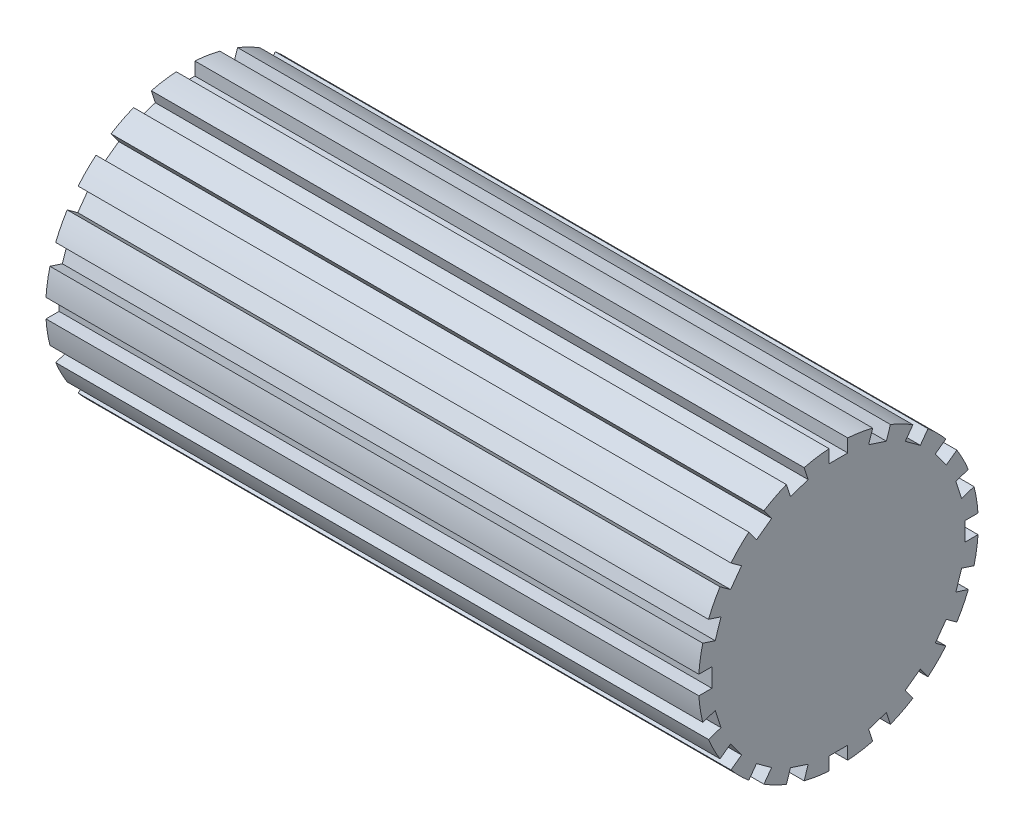
from build123d import *

# Parameters (mm, degrees)
SKETCH1_W          = 44.45
SKETCH1_H          = 9.525
SKETCH2_OUTSIDE_W  = 31.446
SKETCH2_OUTSIDE_H  = 31.446
CUT_EXTRUDE1_DEPTH = 44.45


with BuildPart() as part:
    # Sketch1 → Revolve1 (revolve)
    with BuildSketch(Plane(origin=(0, 0, 0), x_dir=(1, 0, 0), z_dir=(0, 1, 0))):
        with Locations((0, 4.7625)):
            Rectangle(SKETCH1_W, SKETCH1_H)
    revolve(axis=Axis((17.670033956, 0, 0), (-1, 0, 0)))

    # Sketch2 outside → Cut-Extrude1 (cut)
    with BuildSketch(Plane(origin=(22.225, 0, 0), x_dir=(0, 0, -1), z_dir=(1, 0, 0))):
        Rectangle(SKETCH2_OUTSIDE_W, SKETCH2_OUTSIDE_H)
        with BuildLine():
            Line((-0.635, 8.614809762), (0.635, 8.614809762))
            Line((0.635, 8.614809762), (0.635, 9.503809762))
            ThreePointArc((0.635, 9.503809762), (1.49003828, 9.407731444), (2.33291784, 9.234885996))
            Line((2.33291784, 9.234885996), (2.058201732, 8.389396753))
            Line((2.058201732, 8.389396753), (3.266043508, 7.99694517))
            Line((3.266043508, 7.99694517), (3.540759616, 8.842434413))
            ThreePointArc((3.540759616, 8.842434413), (4.32425951, 8.486837143), (5.072473428, 8.061987244))
            Line((5.072473428, 8.061987244), (4.549932338, 7.342771136))
            Line((4.549932338, 7.342771136), (5.577383921, 6.596283866))
            Line((5.577383921, 6.596283866), (6.09992501, 7.315499974))
            ThreePointArc((6.09992501, 7.315499974), (6.735192091, 6.735192091), (7.315499974, 6.09992501))
            Line((7.315499974, 6.09992501), (6.596283866, 5.577383921))
            Line((6.596283866, 5.577383921), (7.342771136, 4.549932338))
            Line((7.342771136, 4.549932338), (8.061987244, 5.072473428))
            ThreePointArc((8.061987244, 5.072473428), (8.486837143, 4.32425951), (8.842434413, 3.540759616))
            Line((8.842434413, 3.540759616), (7.99694517, 3.266043508))
            Line((7.99694517, 3.266043508), (8.389396753, 2.058201732))
            Line((8.389396753, 2.058201732), (9.234885996, 2.33291784))
            ThreePointArc((9.234885996, 2.33291784), (9.407731444, 1.49003828), (9.503809762, 0.635))
            Line((9.503809762, 0.635), (8.614809762, 0.635))
            Line((8.614809762, 0.635), (8.614809762, -0.635))
            Line((8.614809762, -0.635), (9.503809762, -0.635))
            ThreePointArc((9.503809762, -0.635), (9.407731444, -1.49003828), (9.234885996, -2.33291784))
            Line((9.234885996, -2.33291784), (8.389396753, -2.058201732))
            Line((8.389396753, -2.058201732), (7.99694517, -3.266043508))
            Line((7.99694517, -3.266043508), (8.842434413, -3.540759616))
            ThreePointArc((8.842434413, -3.540759616), (8.486837143, -4.32425951), (8.061987244, -5.072473428))
            Line((8.061987244, -5.072473428), (7.342771136, -4.549932338))
            Line((7.342771136, -4.549932338), (6.596283866, -5.577383921))
            Line((6.596283866, -5.577383921), (7.315499974, -6.09992501))
            ThreePointArc((7.315499974, -6.09992501), (6.735192091, -6.735192091), (6.09992501, -7.315499974))
            Line((6.09992501, -7.315499974), (5.577383921, -6.596283866))
            Line((5.577383921, -6.596283866), (4.549932338, -7.342771136))
            Line((4.549932338, -7.342771136), (5.072473428, -8.061987244))
            ThreePointArc((5.072473428, -8.061987244), (4.32425951, -8.486837143), (3.540759616, -8.842434413))
            Line((3.540759616, -8.842434413), (3.266043508, -7.99694517))
            Line((3.266043508, -7.99694517), (2.058201732, -8.389396753))
            Line((2.058201732, -8.389396753), (2.33291784, -9.234885996))
            ThreePointArc((2.33291784, -9.234885996), (1.49003828, -9.407731444), (0.635, -9.503809762))
            Line((0.635, -9.503809762), (0.635, -8.614809762))
            Line((0.635, -8.614809762), (-0.635, -8.614809762))
            Line((-0.635, -8.614809762), (-0.635, -9.503809762))
            ThreePointArc((-0.635, -9.503809762), (-1.49003828, -9.407731444), (-2.33291784, -9.234885996))
            Line((-2.33291784, -9.234885996), (-2.058201732, -8.389396753))
            Line((-2.058201732, -8.389396753), (-3.266043508, -7.99694517))
            Line((-3.266043508, -7.99694517), (-3.540759616, -8.842434413))
            ThreePointArc((-3.540759616, -8.842434413), (-4.32425951, -8.486837143), (-5.072473428, -8.061987244))
            Line((-5.072473428, -8.061987244), (-4.549932338, -7.342771136))
            Line((-4.549932338, -7.342771136), (-5.577383921, -6.596283866))
            Line((-5.577383921, -6.596283866), (-6.09992501, -7.315499974))
            ThreePointArc((-6.09992501, -7.315499974), (-6.735192091, -6.735192091), (-7.315499974, -6.09992501))
            Line((-7.315499974, -6.09992501), (-6.596283866, -5.577383921))
            Line((-6.596283866, -5.577383921), (-7.342771136, -4.549932338))
            Line((-7.342771136, -4.549932338), (-8.061987244, -5.072473428))
            ThreePointArc((-8.061987244, -5.072473428), (-8.486837143, -4.32425951), (-8.842434413, -3.540759616))
            Line((-8.842434413, -3.540759616), (-7.99694517, -3.266043508))
            Line((-7.99694517, -3.266043508), (-8.389396753, -2.058201732))
            Line((-8.389396753, -2.058201732), (-9.234885996, -2.33291784))
            ThreePointArc((-9.234885996, -2.33291784), (-9.407731444, -1.49003828), (-9.503809762, -0.635))
            Line((-9.503809762, -0.635), (-8.614809762, -0.635))
            Line((-8.614809762, -0.635), (-8.614809762, 0.635))
            Line((-8.614809762, 0.635), (-9.503809762, 0.635))
            ThreePointArc((-9.503809762, 0.635), (-9.407731444, 1.49003828), (-9.234885996, 2.33291784))
            Line((-9.234885996, 2.33291784), (-8.389396753, 2.058201732))
            Line((-8.389396753, 2.058201732), (-7.99694517, 3.266043508))
            Line((-7.99694517, 3.266043508), (-8.842434413, 3.540759616))
            ThreePointArc((-8.842434413, 3.540759616), (-8.486837143, 4.32425951), (-8.061987244, 5.072473428))
            Line((-8.061987244, 5.072473428), (-7.342771136, 4.549932338))
            Line((-7.342771136, 4.549932338), (-6.596283866, 5.577383921))
            Line((-6.596283866, 5.577383921), (-7.315499974, 6.09992501))
            ThreePointArc((-7.315499974, 6.09992501), (-6.735192091, 6.735192091), (-6.09992501, 7.315499974))
            Line((-6.09992501, 7.315499974), (-5.577383921, 6.596283866))
            Line((-5.577383921, 6.596283866), (-4.549932338, 7.342771136))
            Line((-4.549932338, 7.342771136), (-5.072473428, 8.061987244))
            ThreePointArc((-5.072473428, 8.061987244), (-4.32425951, 8.486837143), (-3.540759616, 8.842434413))
            Line((-3.540759616, 8.842434413), (-3.266043508, 7.99694517))
            Line((-3.266043508, 7.99694517), (-2.058201732, 8.389396753))
            Line((-2.058201732, 8.389396753), (-2.33291784, 9.234885996))
            ThreePointArc((-2.33291784, 9.234885996), (-1.49003828, 9.407731444), (-0.635, 9.503809762))
            Line((-0.635, 9.503809762), (-0.635, 8.614809762))
        make_face(mode=Mode.SUBTRACT)
    extrude(amount=-CUT_EXTRUDE1_DEPTH, mode=Mode.SUBTRACT)


solid = part.part
